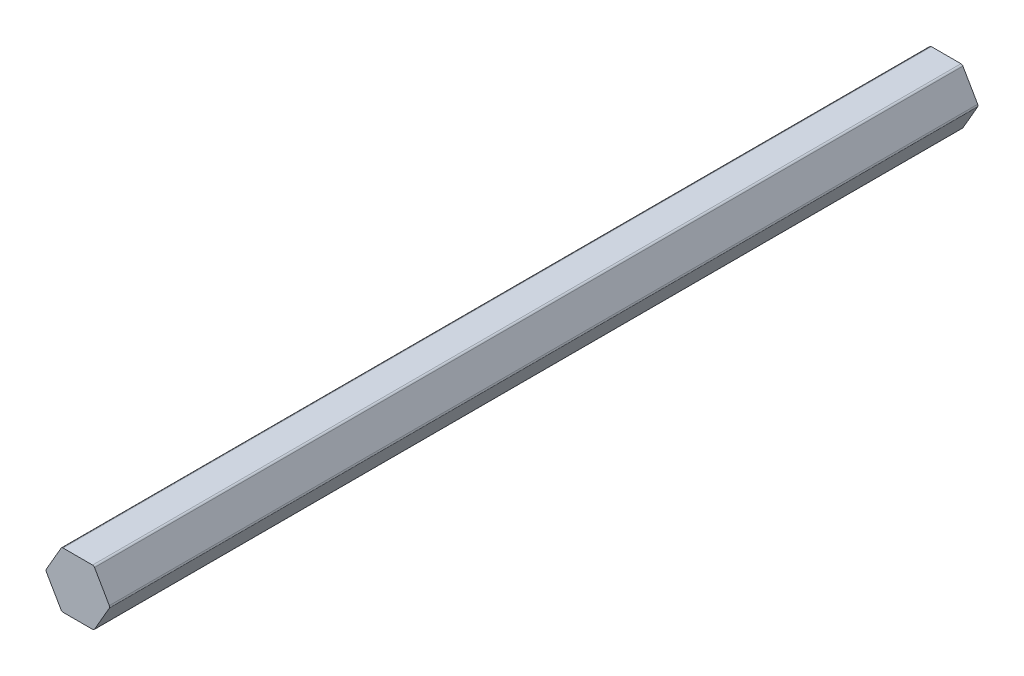
from build123d import *

# Parameters (mm, degrees)
BOSS_EXTRUDE1_DEPTH = 197.612


with BuildPart() as part:
    # Sketch1 → Boss-Extrude1 (new body)
    with BuildSketch(Plane(origin=(0, 0, -228.6), x_dir=(-1, 0, 0), z_dir=(0, 0, -1))):
        with BuildLine():
            Line((3.805488829, -6.0833), (7.171036753, -0.254))
            ThreePointArc((7.171036753, -0.254), (7.239095848, 0), (7.171036753, 0.254))
            Line((7.171036753, 0.254), (3.805488829, 6.0833))
            ThreePointArc((3.805488829, 6.0833), (3.619547924, 6.269240905), (3.365547924, 6.3373))
            Line((3.365547924, 6.3373), (-3.365547924, 6.3373))
            ThreePointArc((-3.365547924, 6.3373), (-3.619547924, 6.269240905), (-3.805488829, 6.0833))
            Line((-3.805488829, 6.0833), (-7.171036753, 0.254))
            ThreePointArc((-7.171036753, 0.254), (-7.239095848, 0), (-7.171036753, -0.254))
            Line((-7.171036753, -0.254), (-3.805488829, -6.0833))
            ThreePointArc((-3.805488829, -6.0833), (-3.619547924, -6.269240905), (-3.365547924, -6.3373))
            Line((-3.365547924, -6.3373), (3.365547924, -6.3373))
            ThreePointArc((3.365547924, -6.3373), (3.619547924, -6.269240905), (3.805488829, -6.0833))
        make_face()
    extrude(amount=-BOSS_EXTRUDE1_DEPTH)


solid = part.part
